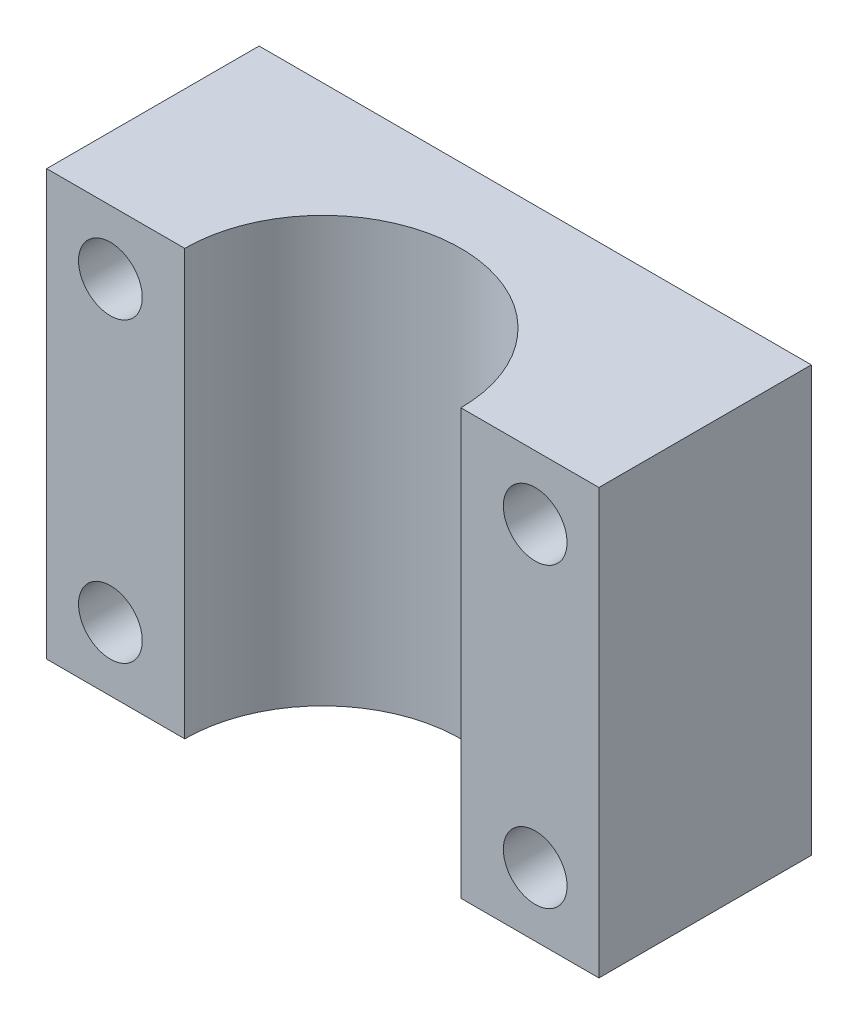
from build123d import *

# Parameters (mm, degrees)
SKETCH1_W           = 26
SKETCH1_H           = 10
BOSS_EXTRUDE1_DEPTH = 20
CUT_EXTRUDE1_DEPTH  = 21
SKETCH3_R           = 1.5
CUT_EXTRUDE2_DEPTH  = 10


with BuildPart() as part:
    # Sketch1 → Boss-Extrude1 (new body)
    with BuildSketch(Plane(origin=(0, 0, 0), x_dir=(1, 0, 0), z_dir=(0, 1, 0))):
        with Locations((13, 5)):
            Rectangle(SKETCH1_W, SKETCH1_H)
    extrude(amount=BOSS_EXTRUDE1_DEPTH)

    # Sketch2 → Cut-Extrude1 (cut, through all)
    with BuildSketch(Plane(origin=(0, 20, 0), x_dir=(1, 0, 0), z_dir=(0, 1, 0))):
        with BuildLine():
            Line((6.5, 0), (19.5, 0))
            ThreePointArc((19.5, 0), (13, 6.5), (6.5, 0))
        make_face()
    extrude(amount=-CUT_EXTRUDE1_DEPTH, mode=Mode.SUBTRACT)

    # Sketch3 → Cut-Extrude2 (cut)
    with BuildSketch(Plane(origin=(0, 0, -10), x_dir=(-1, 0, 0), z_dir=(0, 0, -1))):
        with Locations((-23, 17)):
            Circle(SKETCH3_R)
        with Locations((-3, 17)):
            Circle(SKETCH3_R)
        with Locations((-3, 3)):
            Circle(SKETCH3_R)
        with Locations((-23, 3)):
            Circle(SKETCH3_R)
    extrude(amount=-CUT_EXTRUDE2_DEPTH, mode=Mode.SUBTRACT)


solid = part.part
